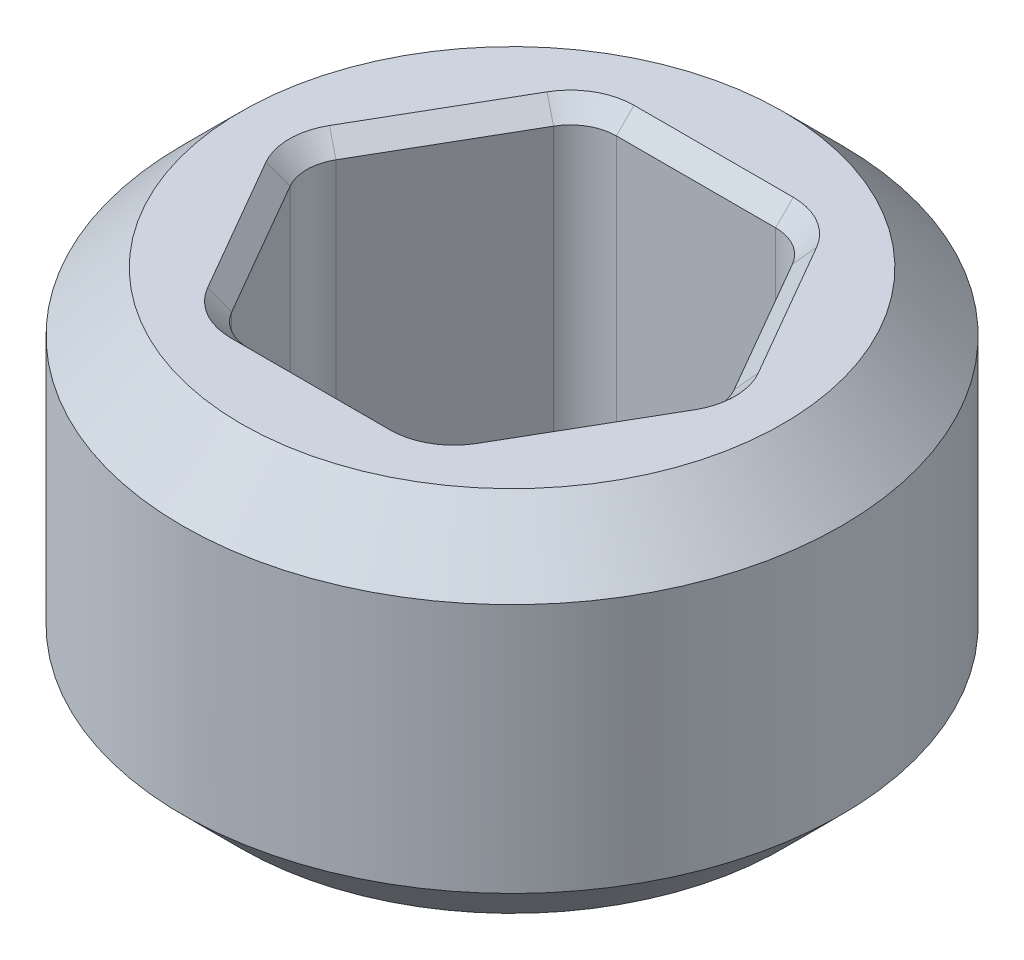
from build123d import *

# Parameters (mm, degrees)
SKETCH1_W               = 1.4224
SKETCH1_H               = 1.5875
CUT_EXTRUDE1_DEPTH      = 1.79375
CUT_EXTRUDE1_DEPTH_BACK = 1.79375
FILLET1_R               = 0.1984375
CHAMFER1_SIZE           = 0.254
CHAMFER2_SIZE           = 0.0762


with BuildPart() as part:
    # Sketch1 → Revolve1 (revolve)
    with BuildSketch(Plane.XY):
        with Locations((0.7112, 0)):
            Rectangle(SKETCH1_W, SKETCH1_H)
    revolve(axis=Axis((0, -1.704166029, 0), (0, 1, 0)))

    # Sketch3 → Cut-Extrude1 (cut, two sides)
    with BuildSketch(Plane(origin=(0, 0, 0), x_dir=(1, 0, 0), z_dir=(0, 1, 0))) as cut_extrude1_sk:
        Polygon((0.916543552, 0), (0.458271776, 0.79375), (-0.458271776, 0.79375), (-0.916543552, 0), (-0.458271776, -0.79375), (0.458271776, -0.79375), align=None)
    extrude(amount=CUT_EXTRUDE1_DEPTH, mode=Mode.SUBTRACT)
    extrude(cut_extrude1_sk.sketch, amount=-CUT_EXTRUDE1_DEPTH_BACK, mode=Mode.SUBTRACT)

    # Fillet1
    fillet1_edges = [part.edges().sort_by_distance(p)[0] for p in [
        (0.458271776, 0, -0.79375),
        (0.916543552, 0, 0),
        (0.458271776, 0, 0.79375),
        (-0.458271776, 0, 0.79375),
        (-0.916543552, 0, 0),
        (-0.458271776, 0, -0.79375),
    ]]
    fillet(fillet1_edges, radius=FILLET1_R)

    # Chamfer1
    chamfer1_edges = [part.edges().sort_by_distance(p)[0] for p in [
        (-1.4224, 0.79375, 0),
        (-1.4224, -0.79375, 0),
    ]]
    chamfer(chamfer1_edges, length=CHAMFER1_SIZE)

    # Chamfer2
    chamfer2_edges = [part.edges().sort_by_distance(p)[0] for p in [
        (0.687407664, -0.79375, -0.396875),
        (0.687407664, 0.79375, -0.396875),
        (0.687407664, -0.79375, 0.396875),
        (0.687407664, 0.79375, 0.396875),
        (0, -0.79375, 0.79375),
        (0, 0.79375, 0.79375),
        (-0.687407664, -0.79375, 0.396875),
        (-0.687407664, 0.79375, 0.396875),
        (-0.687407664, -0.79375, -0.396875),
        (-0.687407664, 0.79375, -0.396875),
        (0, -0.79375, -0.79375),
        (0, 0.79375, -0.79375),
        (0.885845164, 0.79375, 0),
        (0.885845164, -0.79375, 0),
        (0.442922582, 0.79375, 0.767164416),
        (0.442922582, -0.79375, 0.767164416),
        (-0.442922582, 0.79375, 0.767164416),
        (-0.442922582, -0.79375, 0.767164416),
        (-0.885845164, 0.79375, 0),
        (-0.885845164, -0.79375, 0),
        (-0.442922582, 0.79375, -0.767164416),
        (-0.442922582, -0.79375, -0.767164416),
        (0.442922582, 0.79375, -0.767164416),
        (0.442922582, -0.79375, -0.767164416),
    ]]
    chamfer(chamfer2_edges, length=CHAMFER2_SIZE)


solid = part.part
